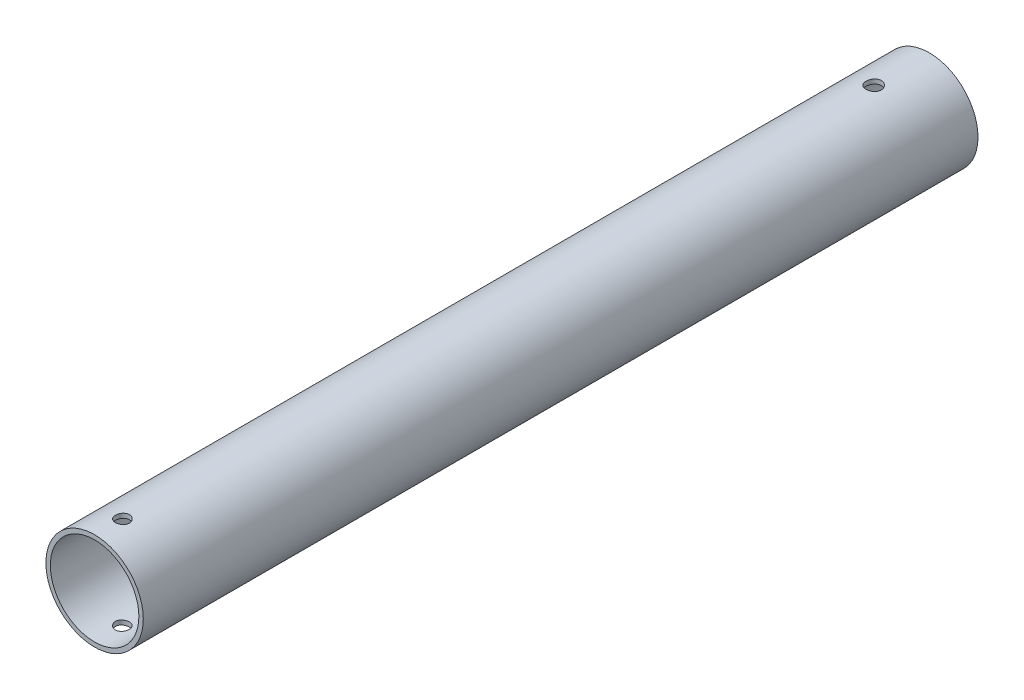
from build123d import *

# Parameters (mm, degrees)
SKETCH1_R               = 17.5
SKETCH1_R_2             = 15.9125
BOSS_EXTRUDE1_DEPTH     = 150
SKETCH5_W               = 2.75
SKETCH5_H               = 17.5
SKETCH6_R               = 2.5
CUT_EXTRUDE1_DEPTH      = 18.5000001
CUT_EXTRUDE1_DEPTH_BACK = 18.5000001


with BuildPart() as part:
    # Sketch1 → Boss-Extrude1 (new body, symmetric)
    with BuildSketch(Plane.XY):
        Circle(SKETCH1_R)
        Circle(SKETCH1_R_2, mode=Mode.SUBTRACT)
    extrude(amount=BOSS_EXTRUDE1_DEPTH, both=True)

    # Sketch5 → M5 Clearance Hole1 (revolve, cut)
    with BuildSketch(Plane(origin=(0, 0, -130), x_dir=(0, 0, -1), z_dir=(1, 0, 0))):
        with Locations((1.375, 8.75)):
            Rectangle(SKETCH5_W, SKETCH5_H)
    m5_clearance_hole1 = revolve(axis=Axis((0, -6.35, -130), (0, 1, 0)), mode=Mode.SUBTRACT)

    # Mirror1: M5 Clearance Hole1 across plane
    add(m5_clearance_hole1.mirror(Plane.ZX), mode=Mode.SUBTRACT)

    # Sketch6 → Cut-Extrude1 (cut, two sides)
    with BuildSketch(Plane(origin=(0, 0, 0), x_dir=(1, 0, 0), z_dir=(0, 1, 0))) as cut_extrude1_sk:
        with Locations((0, -140)):
            Circle(SKETCH6_R)
    extrude(amount=CUT_EXTRUDE1_DEPTH, mode=Mode.SUBTRACT)
    extrude(cut_extrude1_sk.sketch, amount=-CUT_EXTRUDE1_DEPTH_BACK, mode=Mode.SUBTRACT)


solid = part.part
